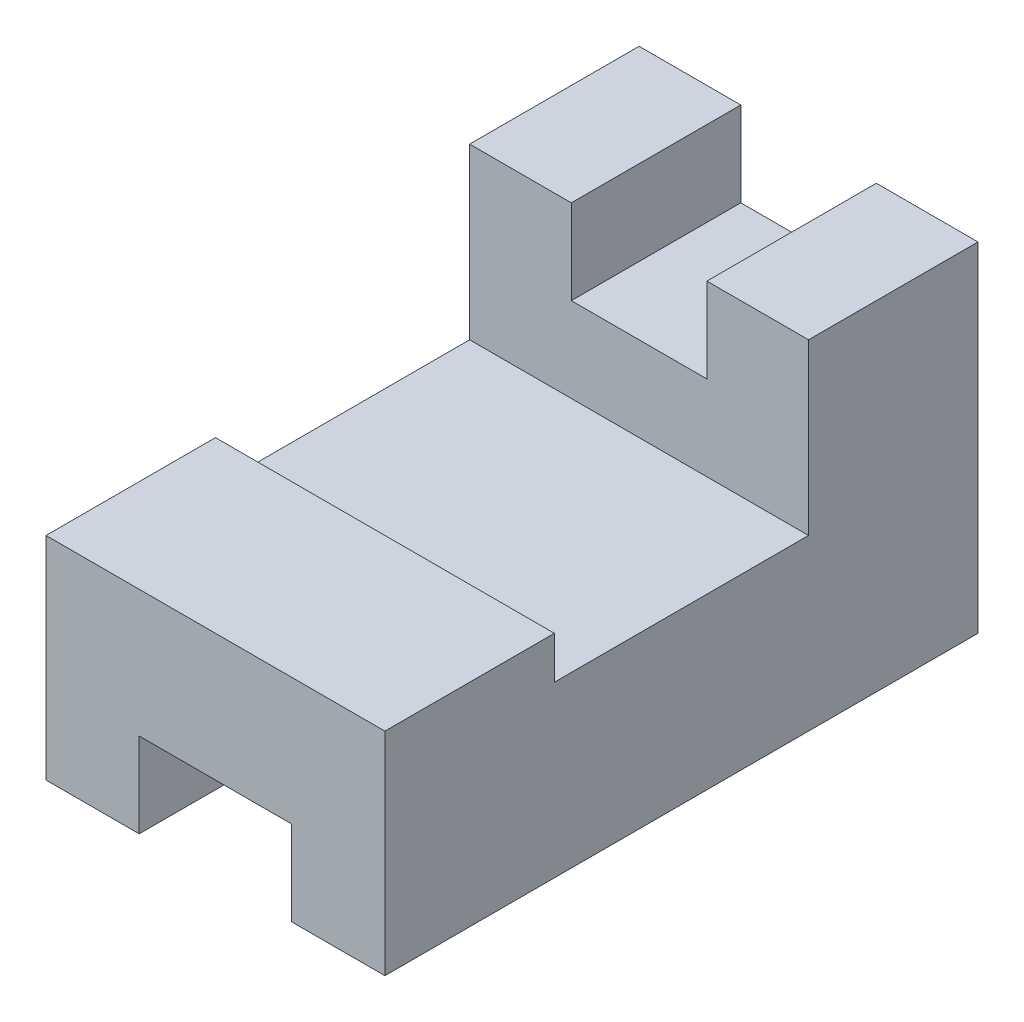
from build123d import *

# Parameters (mm, degrees)
IZIM1_W                     = 40
IZIM1_H                     = 70
Y_KSEKLIK_EKSTR_ZYON1_DEPTH = 20
IZIM2_W                     = 18
IZIM2_H                     = 10
KES_EKSTR_ZYON1_DEPTH       = 71
IZIM3_W                     = 40
IZIM3_H                     = 20
Y_KSEKLIK_EKSTR_ZYON2_DEPTH = 5
IZIM4_W                     = 40
IZIM4_H                     = 20
Y_KSEKLIK_EKSTR_ZYON3_DEPTH = 20
IZIM5_W                     = 16
IZIM5_H                     = 10
KES_EKSTR_ZYON2_DEPTH       = 21


with BuildPart() as part:
    # Çizim1 → Yükseklik-Ekstrüzyon1 (new body)
    with BuildSketch(Plane(origin=(0, 0, 0), x_dir=(1, 0, 0), z_dir=(0, 1, 0))):
        Rectangle(IZIM1_W, IZIM1_H)
    extrude(amount=Y_KSEKLIK_EKSTR_ZYON1_DEPTH)

    # Çizim2 → Kes-Ekstrüzyon1 (cut, through all)
    with BuildSketch(Plane.XY.offset(35)):
        with Locations((0, 5)):
            Rectangle(IZIM2_W, IZIM2_H)
    extrude(amount=-KES_EKSTR_ZYON1_DEPTH, mode=Mode.SUBTRACT)

    # Çizim3 → Yükseklik-Ekstrüzyon2 (add)
    with BuildSketch(Plane(origin=(0, 20, 0), x_dir=(1, 0, 0), z_dir=(0, 1, 0))):
        with Locations((0, -25)):
            Rectangle(IZIM3_W, IZIM3_H)
    extrude(amount=Y_KSEKLIK_EKSTR_ZYON2_DEPTH)

    # Çizim4 → Yükseklik-Ekstrüzyon3 (add)
    with BuildSketch(Plane(origin=(0, 20, 0), x_dir=(1, 0, 0), z_dir=(0, 1, 0))):
        with Locations((0, 25)):
            Rectangle(IZIM4_W, IZIM4_H)
    extrude(amount=Y_KSEKLIK_EKSTR_ZYON3_DEPTH)

    # Çizim5 → Kes-Ekstrüzyon2 (cut, through all)
    with BuildSketch(Plane.XY.offset(-15)):
        with Locations((0, 35)):
            Rectangle(IZIM5_W, IZIM5_H)
    extrude(amount=-KES_EKSTR_ZYON2_DEPTH, mode=Mode.SUBTRACT)


solid = part.part
